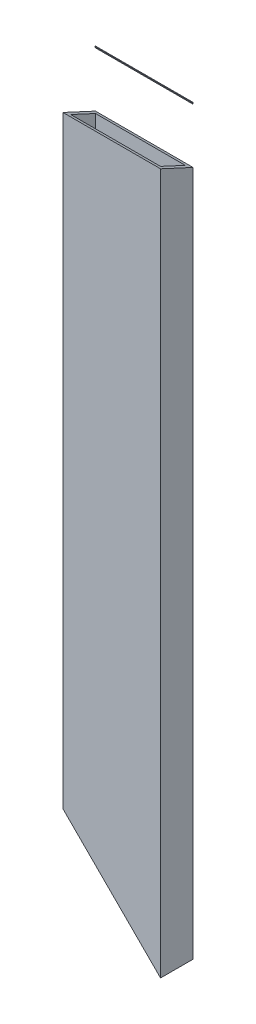
from build123d import *

# Parameters (mm, degrees)
SKETCH1_W               = 76.2
SKETCH1_H               = 25.4
SKETCH1_W_2             = 70.104
SKETCH1_H_2             = 19.304
BOSS_EXTRUDE1_DEPTH     = 503
SKETCH3_W               = 76.2
SKETCH3_H               = 25.4
SKETCH3_W_2             = 70.104
SKETCH3_H_2             = 19.304
BOSS_EXTRUDE2_DEPTH     = 38.1
SKETCH4_W               = 76.2
SKETCH4_H               = 25.4
SKETCH4_W_2             = 70.104
SKETCH4_H_2             = 19.304
BOSS_EXTRUDE3_DEPTH     = 38.1
CUT_EXTRUDE1_DEPTH      = 13.7
CUT_EXTRUDE1_DEPTH_BACK = 13.7
CUT_EXTRUDE2_DEPTH      = 77.2


with BuildPart() as part:
    # Sketch1 → Boss-Extrude1 (new body)
    with BuildSketch(Plane(origin=(0, 0, 0), x_dir=(1, 0, 0), z_dir=(0, 1, 0))):
        Rectangle(SKETCH1_W, SKETCH1_H)
        Rectangle(SKETCH1_W_2, SKETCH1_H_2, mode=Mode.SUBTRACT)
    extrude(amount=BOSS_EXTRUDE1_DEPTH)

    # Sketch3 → Boss-Extrude2 (add)
    with BuildSketch(Plane.XZ):
        Rectangle(SKETCH3_W, SKETCH3_H)
        Rectangle(SKETCH3_W_2, SKETCH3_H_2, mode=Mode.SUBTRACT)
    extrude(amount=BOSS_EXTRUDE2_DEPTH)

    # Sketch4 → Boss-Extrude3 (add)
    with BuildSketch(Plane(origin=(0, 503, 0), x_dir=(1, 0, 0), z_dir=(0, 1, 0))):
        Rectangle(SKETCH4_W, SKETCH4_H)
        Rectangle(SKETCH4_W_2, SKETCH4_H_2, mode=Mode.SUBTRACT)
    extrude(amount=BOSS_EXTRUDE3_DEPTH)

    # Sketch5 → Cut-Extrude1 (cut, two sides)
    with BuildSketch(Plane.XY) as cut_extrude1_sk:
        Polygon((-63.704425498, 63.824156123), (106.559138903, -106.632014079), (-66.404910458, -106.632014079), align=None)
    extrude(amount=CUT_EXTRUDE1_DEPTH, mode=Mode.SUBTRACT)
    extrude(cut_extrude1_sk.sketch, amount=-CUT_EXTRUDE1_DEPTH_BACK, mode=Mode.SUBTRACT)

    # Sketch6 → Cut-Extrude2 (cut, through all)
    with BuildSketch(Plane(origin=(38.1, 0, 0), x_dir=(0, 0, -1), z_dir=(1, 0, 0))):
        Polygon((33.51840798, 487.450611994), (-43.414005654, 523.140014383), (0, 598.23299359), (10.634909231, 545.017601807), align=None)
    extrude(amount=-CUT_EXTRUDE2_DEPTH, mode=Mode.SUBTRACT)


solid = part.part
